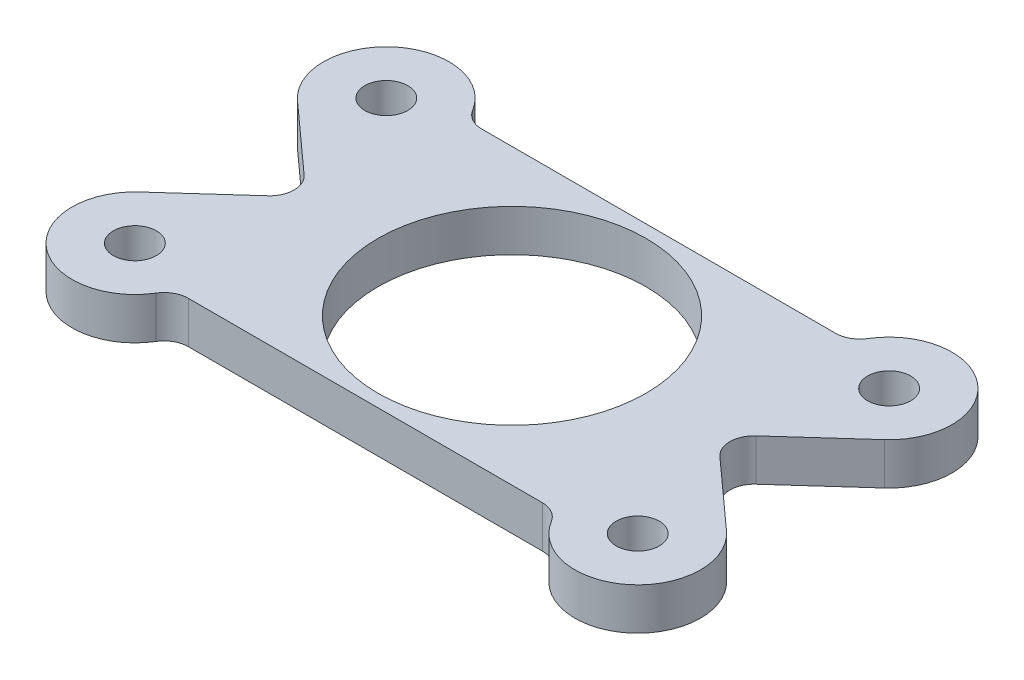
from build123d import *

# Parameters (mm, degrees)
SKETCH1_R             = 10.16
BOSS_EXTRUDE1_DEPTH   = 3.175
F_4_CLEARANCE_HOLE1_D = 3.2639
FILLET1_R             = 1.8415


with BuildPart() as part:
    # Sketch1 → Boss-Extrude1 (new body)
    with BuildSketch(Plane(origin=(0, 0, 0), x_dir=(1, 0, 0), z_dir=(0, 1, 0))):
        with BuildLine():
            Line((-22.240359722, 5.989040287), (-17.117894241, 1.367237756))
            ThreePointArc((-17.117894241, 1.367237756), (-16.51, 0), (-17.117894241, -1.367237756))
            Line((-17.117894241, -1.367237756), (-22.240359722, -5.989040287))
            ThreePointArc((-22.240359722, -5.989040287), (-21.692878978, -13.486893103), (-14.559871939, -11.1125))
            Line((-14.559871939, -11.1125), (14.559871939, -11.1125))
            ThreePointArc((14.559871939, -11.1125), (21.692878978, -13.486893103), (22.240359722, -5.989040287))
            Line((22.240359722, -5.989040287), (17.117894241, -1.367237756))
            ThreePointArc((17.117894241, -1.367237756), (16.51, 0), (17.117894241, 1.367237756))
            Line((17.117894241, 1.367237756), (22.240359722, 5.989040287))
            ThreePointArc((22.240359722, 5.989040287), (21.692878978, 13.486893103), (14.559871939, 11.1125))
            Line((14.559871939, 11.1125), (-14.559871939, 11.1125))
            ThreePointArc((-14.559871939, 11.1125), (-21.692878978, 13.486893103), (-22.240359722, 5.989040287))
        make_face()
        with Locations(Location((0, 0, 0), (0, 0, 270))):  # turned: the seam where the file's is
            Circle(SKETCH1_R, mode=Mode.SUBTRACT)
    extrude(amount=BOSS_EXTRUDE1_DEPTH)

    # #4 Clearance Hole1 (through all)
    with Locations(Plane(origin=(0, 3.175, 0), x_dir=(1, 0, 0), z_dir=(0, 1, 0))):
        with Locations((-19.05, 9.525), (-19.05, -9.525), (19.05, -9.525), (19.05, 9.525)):
            Hole(F_4_CLEARANCE_HOLE1_D / 2)

    # Fillet1
    fillet1_edges = [part.edges().sort_by_distance(p)[0] for p in [
        (14.559871939, 1.5875, 11.1125),
        (-14.559871939, 1.5875, 11.1125),
        (-14.559871939, 1.5875, -11.1125),
        (14.559871939, 1.5875, -11.1125),
    ]]
    fillet(fillet1_edges, radius=FILLET1_R)


solid = part.part
